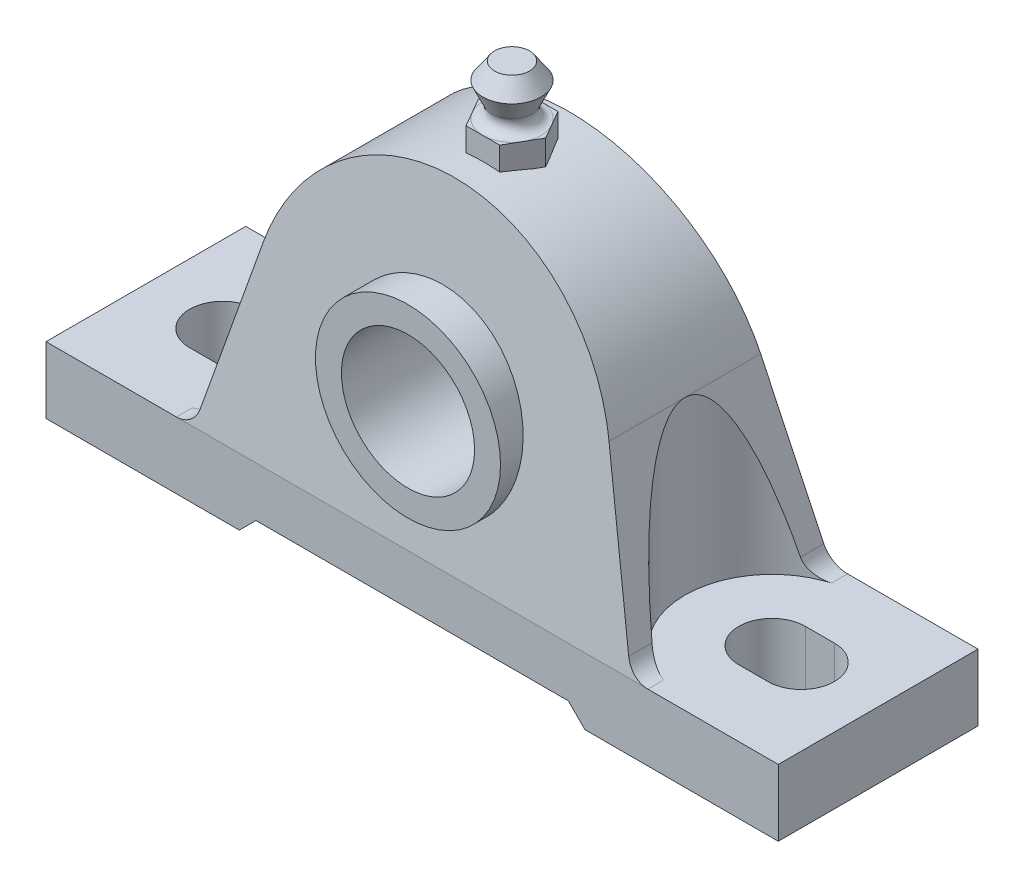
from build123d import *

# Parameters (mm, degrees)
SKETCH1_R               = 17.653
SKETCH1_R_2             = 12.7
EXTRUDE1_DEPTH          = 19.84375
EXTRUDE1_DEPTH_BACK     = 14.2875
SKETCH2_R               = 17.653
EXTRUDE2_DEPTH          = 19.05
CUT_EXTRUDE1_DEPTH      = 35.13125
CUT_EXTRUDE1_DEPTH_BACK = 37.5125
CUT_EXTRUDE2_DEPTH      = 35.13125
CUT_EXTRUDE2_DEPTH_BACK = 23.8125
CUT_EXTRUDE3_DEPTH      = 70.85
EXTRUDE3_DEPTH          = 4.7625


with BuildPart() as part:
    # Sketch1 → Extrude1 (new body, two sides)
    with BuildSketch(Plane.XY) as extrude1_sk:
        Circle(SKETCH1_R)
        Circle(SKETCH1_R_2, mode=Mode.SUBTRACT)
    extrude(amount=EXTRUDE1_DEPTH)
    extrude(extrude1_sk.sketch, amount=-EXTRUDE1_DEPTH_BACK)


with BuildPart() as body_2:
    # Sketch2 → Extrude2 (new body, symmetric)
    with BuildSketch(Plane.XY):
        with BuildLine():
            Line((-32.968255859, 8.833817533), (-40.875075195, -20.674833958))
            ThreePointArc((-40.875075195, -20.674833958), (-42.387071144, -22.937695807), (-44.964161193, -23.8125))
            Line((-44.964161193, -23.8125), (-69.85, -23.8125))
            Line((-69.85, -23.8125), (-69.85, -36.5125))
            Line((-69.85, -36.5125), (-32.968255859, -36.5125))
            Line((-32.968255859, -36.5125), (-29.793255859, -33.3375))
            Line((-29.793255859, -33.3375), (29.793255859, -33.3375))
            Line((29.793255859, -33.3375), (32.968255859, -36.5125))
            Line((32.968255859, -36.5125), (69.85, -36.5125))
            Line((69.85, -36.5125), (69.85, -23.8125))
            Line((69.85, -23.8125), (44.964161193, -23.8125))
            ThreePointArc((44.964161193, -23.8125), (42.387071144, -22.937695807), (40.875075195, -20.674833958))
            Line((40.875075195, -20.674833958), (32.968255859, 8.833817533))
            ThreePointArc((32.968255859, 8.833817533), (0, 34.13125), (-32.968255859, 8.833817533))
        make_face()
        Circle(SKETCH2_R, mode=Mode.SUBTRACT)
    extrude(amount=EXTRUDE2_DEPTH, both=True)

    # Sketch3 → Cut-Extrude1 (cut, two sides)
    with BuildSketch(Plane(origin=(0, 0, 0), x_dir=(1, 0, 0), z_dir=(0, 1, 0))) as cut_extrude1_sk:
        with BuildLine():
            Line((-55.165625, 6.35), (-49.609375, 6.35))
            ThreePointArc((-49.609375, 6.35), (-43.259375, 0), (-49.609375, -6.35))
            Line((-49.609375, -6.35), (-55.165625, -6.35))
            ThreePointArc((-55.165625, -6.35), (-61.515625, 0), (-55.165625, 6.35))
        make_face()
        with BuildLine():
            Line((49.609375, -6.35), (55.165625, -6.35))
            ThreePointArc((55.165625, -6.35), (61.515625, 0), (55.165625, 6.35))
            Line((55.165625, 6.35), (49.609375, 6.35))
            ThreePointArc((49.609375, 6.35), (43.259375, 0), (49.609375, -6.35))
        make_face()
    extrude(amount=CUT_EXTRUDE1_DEPTH, mode=Mode.SUBTRACT)
    extrude(cut_extrude1_sk.sketch, amount=-CUT_EXTRUDE1_DEPTH_BACK, mode=Mode.SUBTRACT)

    # Sketch4 → Cut-Extrude2 (cut, two sides)
    with BuildSketch(Plane(origin=(0, 0, 0), x_dir=(1, 0, 0), z_dir=(0, 1, 0))) as cut_extrude2_sk:
        with BuildLine():
            Line((43.746908834, 15.574284469), (69.85, 25.4))
            Line((69.85, 25.4), (69.85, -25.4))
            Line((69.85, -25.4), (43.746908834, -15.574284469))
            ThreePointArc((43.746908834, -15.574284469), (32.968255859, 0), (43.746908834, 15.574284469))
        make_face()
        with BuildLine():
            Line((-43.746908834, -15.574284469), (-69.85, -25.4))
            Line((-69.85, -25.4), (-69.85, 25.4))
            Line((-69.85, 25.4), (-43.746908834, 15.574284469))
            ThreePointArc((-43.746908834, 15.574284469), (-32.968255859, 0), (-43.746908834, -15.574284469))
        make_face()
    extrude(amount=CUT_EXTRUDE2_DEPTH, mode=Mode.SUBTRACT)
    extrude(cut_extrude2_sk.sketch, amount=-CUT_EXTRUDE2_DEPTH_BACK, mode=Mode.SUBTRACT)

    # Sketch5 → Cut-Extrude3 (cut, symmetric)
    with BuildSketch(Plane(origin=(0, 0, 0), x_dir=(0, 0, -1), z_dir=(1, 0, 0))):
        Polygon((-19.05, -23.8125), (-10.906537009, 34.13125), (-19.05, 34.13125), align=None)
    cut_extrude3 = extrude(amount=CUT_EXTRUDE3_DEPTH, both=True, mode=Mode.SUBTRACT)

    # Mirror1: Cut-Extrude3 across plane
    add(cut_extrude3.mirror(Plane.XY), mode=Mode.SUBTRACT)



with BuildPart() as body_3:
    # Sketch6 → Revolve1 (revolve)
    with BuildSketch(Plane.XY):
        with BuildLine():
            Line((0, 33.675960454), (-5.55625, 33.675960454))
            Line((-5.55625, 33.675960454), (-5.55625, 38.438460454))
            ThreePointArc((-5.55625, 38.438460454), (-3.965277045, 39.311298106), (-3.846591708, 41.122086416))
            Line((-3.846591708, 41.122086416), (-5.55625, 44.788460454))
            Line((-5.55625, 44.788460454), (-3.333091066, 47.963460454))
            Line((-3.333091066, 47.963460454), (0, 47.963460454))
            Line((0, 47.963460454), (0, 33.675960454))
        make_face()
    revolve(axis=Axis((0, 34.13125, 0), (0, 1, 0)))


with BuildPart() as body_2_1:
    add(body_2.part)

    add(body_3.part)  # Extrude3 merges body 3
    # Sketch7 → Extrude3 (add)
    with BuildSketch(Plane.XZ.offset(-33.675960454)):
        Polygon((-3.207902433, 5.55625), (-6.415804866, 0), (-3.207902433, -5.55625), (3.207902433, -5.55625), (6.415804866, 0), (3.207902433, 5.55625), align=None)
    extrude(amount=-EXTRUDE3_DEPTH)


solid = Compound([part.part, body_2_1.part])
